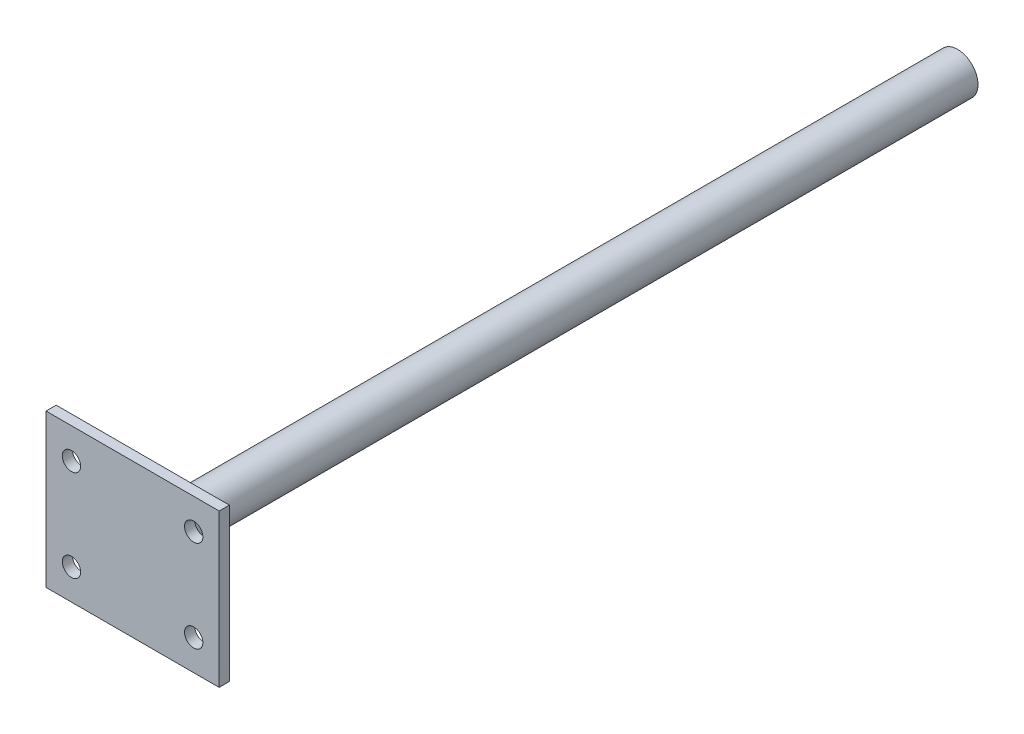
from build123d import *

# Parameters (mm, degrees)
SKETCH1_W           = 34
SKETCH1_H           = 30
SKETCH1_R           = 1.8
BOSS_EXTRUDE1_DEPTH = 2
SCALE1_SCALE        = 1.25
SKETCH2_R           = 5
BOSS_EXTRUDE3_DEPTH = 200
FILLET2_R           = 2


with BuildPart() as part:
    # Sketch1 → Boss-Extrude1 (new body)
    with BuildSketch(Plane.XY):
        Rectangle(SKETCH1_W, SKETCH1_H)
        with Locations((-12, 9)):
            Circle(SKETCH1_R, mode=Mode.SUBTRACT)
        with Locations((12, 9)):
            Circle(SKETCH1_R, mode=Mode.SUBTRACT)
        with Locations((12, -9)):
            Circle(SKETCH1_R, mode=Mode.SUBTRACT)
        with Locations((-12, -9)):
            Circle(SKETCH1_R, mode=Mode.SUBTRACT)
    extrude(amount=BOSS_EXTRUDE1_DEPTH)


with BuildPart() as part_1:
    # Scale1: scaled about (0, 0, 1)
    add(part.part.scale(SCALE1_SCALE).moved(Location((0, 0, -0.25))))

    # Sketch2 → Boss-Extrude3 (add)
    with BuildSketch(Plane(origin=(0, 0, -0.25), x_dir=(-1, 0, 0), z_dir=(0, 0, -1))):
        Circle(SKETCH2_R)
    extrude(amount=BOSS_EXTRUDE3_DEPTH)

    # Fillet2
    fillet2_edges = [part_1.edges().sort_by_distance(p)[0] for p in [
        (5, 0, -0.25),
    ]]
    fillet(fillet2_edges, radius=FILLET2_R)


solid = part_1.part
